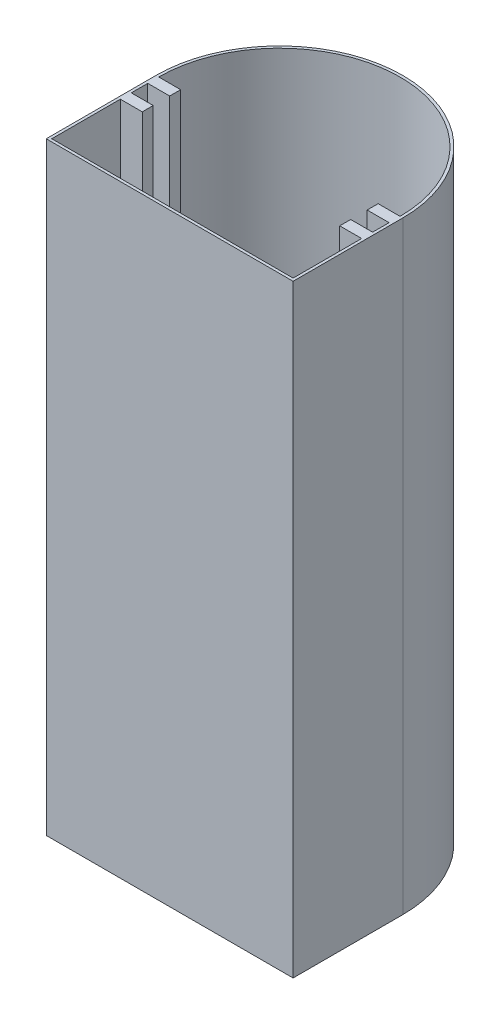
from build123d import *

# Parameters (mm, degrees)
BOSS_EXTRUDE1_DEPTH = 110
CUT_EXTRUDE1_DEPTH  = 109.5
SKETCH3_R           = 2.875
CUT_EXTRUDE2_DEPTH  = 5


with BuildPart() as part:
    # Sketch1 → Boss-Extrude1 (new body)
    with BuildSketch(Plane(origin=(0, 0, 0), x_dir=(1, 0, 0), z_dir=(0, 1, 0))):
        with BuildLine():
            Line((-43.883093525, -1.707733813), (1.116906475, -1.707733813))
            Line((1.116906475, -1.707733813), (1.116906475, 18.292266187))
            ThreePointArc((1.116906475, 18.292266187), (-21.383093525, 40.792266187), (-43.883093525, 18.292266187))
            Line((-43.883093525, 18.292266187), (-43.883093525, -1.707733813))
        make_face()
    extrude(amount=BOSS_EXTRUDE1_DEPTH)

    # Sketch2 → Cut-Extrude1 (cut)
    with BuildSketch(Plane(origin=(0, 110, 0), x_dir=(1, 0, 0), z_dir=(0, 1, 0))):
        with BuildLine():
            Line((-43.383093525, 16.292266187), (-43.383093525, 13.292266187))
            Line((-43.383093525, 13.292266187), (-39.383093525, 13.292266187))
            Line((-39.383093525, 13.292266187), (-39.383093525, 11.292266187))
            Line((-39.383093525, 11.292266187), (-43.383093525, 11.292266187))
            Line((-43.383093525, 11.292266187), (-43.383093525, -1.207733813))
            Line((-43.383093525, -1.207733813), (0.616906475, -1.207733813))
            Line((0.616906475, -1.207733813), (0.616906475, 11.292266187))
            Line((0.616906475, 11.292266187), (-3.383093525, 11.292266187))
            Line((-3.383093525, 11.292266187), (-3.383093525, 13.292266187))
            Line((-3.383093525, 13.292266187), (0.616906475, 13.292266187))
            Line((0.616906475, 13.292266187), (0.616906475, 16.292266187))
            Line((0.616906475, 16.292266187), (-3.383093525, 16.292266187))
            Line((-3.383093525, 16.292266187), (-3.383093525, 18.292266187))
            Line((-3.383093525, 18.292266187), (0.616906475, 18.292266187))
            ThreePointArc((0.616906475, 18.292266187), (-21.383093525, 40.292266187), (-43.383093525, 18.292266187))
            Line((-43.383093525, 18.292266187), (-39.383093525, 18.292266187))
            Line((-39.383093525, 18.292266187), (-39.383093525, 16.292266187))
            Line((-39.383093525, 16.292266187), (-43.383093525, 16.292266187))
        make_face()
    extrude(amount=-CUT_EXTRUDE1_DEPTH, mode=Mode.SUBTRACT)

    # Sketch3 → Cut-Extrude2 (cut)
    with BuildSketch(Plane.ZY.offset(43.883093525)):
        with Locations((-4.958932854, 55)):
            Circle(SKETCH3_R)
    extrude(amount=-CUT_EXTRUDE2_DEPTH, mode=Mode.SUBTRACT)


solid = part.part
